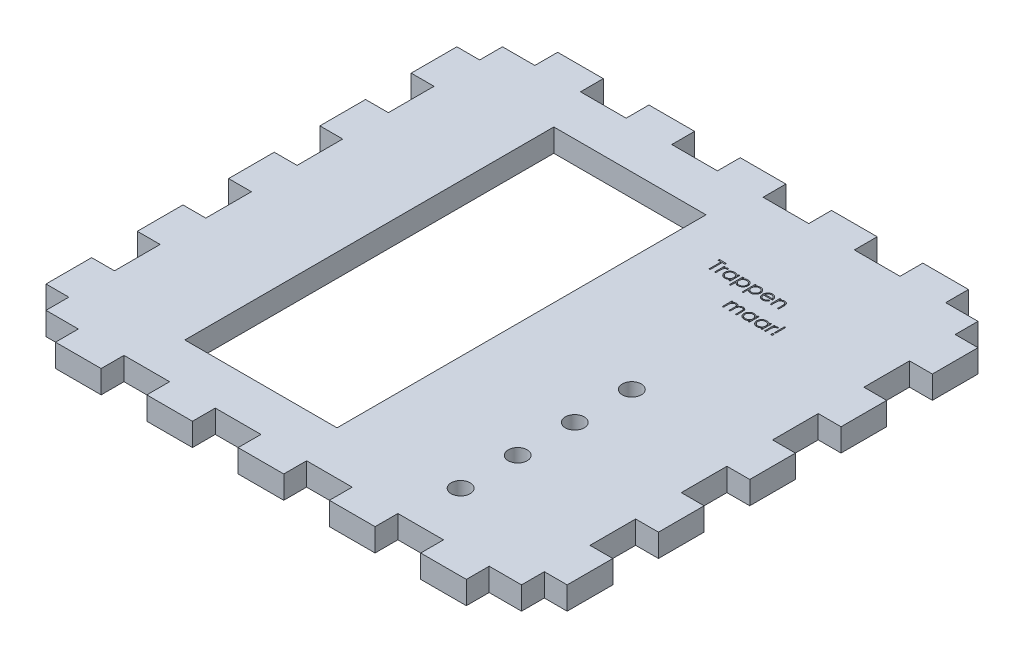
from build123d import *

# Parameters (mm, degrees)
SKETCH1_R           = 2.5
SKETCH1_W           = 40
SKETCH1_H           = 97
BOSS_EXTRUDE2_DEPTH = 6
SKETCH2_W           = 0.314102564
SKETCH2_H           = 2.692307693
CUT_EXTRUDE1_DEPTH  = 7


with BuildPart() as part:
    # Sketch1 → Boss-Extrude2 (new body)
    with BuildSketch(Plane(origin=(0, 0, 0), x_dir=(1, 0, 0), z_dir=(0, 1, 0))):
        Polygon((-62.5, -60), (-54, -60), (-54, -66), (-42, -66), (-42, -60), (-30, -60), (-30, -66), (-18, -66), (-18, -60), (-6, -60), (-6, -66), (6, -66), (6, -60), (18, -60), (18, -66), (30, -66), (30, -60), (42, -60), (42, -66), (54, -66), (54, -60), (62.5, -60), (62.5, -54), (68.5, -54), (68.5, -42), (62.5, -42), (62.5, -30), (68.5, -30), (68.5, -18), (62.5, -18), (62.5, -6), (68.5, -6), (68.5, 6), (62.5, 6), (62.5, 18), (68.5, 18), (68.5, 30), (62.5, 30), (62.5, 42), (68.5, 42), (68.5, 54), (62.5, 54), (62.5, 60), (54, 60), (54, 66), (42, 66), (42, 60), (30, 60), (30, 66), (18, 66), (18, 60), (6, 60), (6, 66), (-6, 66), (-6, 60), (-18, 60), (-18, 66), (-30, 66), (-30, 60), (-42, 60), (-42, 66), (-54, 66), (-54, 60), (-62.5, 60), (-62.5, 54), (-68.5, 54), (-68.5, 42), (-62.5, 42), (-62.5, 30), (-68.5, 30), (-68.5, 18), (-62.5, 18), (-62.5, 6), (-68.5, 6), (-68.5, -6), (-62.5, -6), (-62.5, -18), (-68.5, -18), (-68.5, -30), (-62.5, -30), (-62.5, -42), (-68.5, -42), (-68.5, -54), (-62.5, -54), align=None)
        with Locations((32.5, -46)):
            Circle(SKETCH1_R, mode=Mode.SUBTRACT)
        with Locations((32.5, -31)):
            Circle(SKETCH1_R, mode=Mode.SUBTRACT)
        with Locations((32.5, -16)):
            Circle(SKETCH1_R, mode=Mode.SUBTRACT)
        with Locations((32.5, -1)):
            Circle(SKETCH1_R, mode=Mode.SUBTRACT)
        with Locations((-17.5, 0)):
            Rectangle(SKETCH1_W, SKETCH1_H, mode=Mode.SUBTRACT)
    extrude(amount=BOSS_EXTRUDE2_DEPTH)

    # Sketch2 → Cut-Extrude1 (cut, through all)
    with BuildSketch(Plane(origin=(0, 6, 0), x_dir=(1, 0, 0), z_dir=(0, 1, 0))):
        Polygon((14.440306719, 39.731965066), (14.440306719, 40.090939425), (16.280050309, 40.090939425), (16.280050309, 39.731965066), (15.517229796, 39.731965066), (15.517229796, 36.590939425), (15.203127232, 36.590939425), (15.203127232, 39.731965066), align=None)
        with BuildLine():
            Line((16.639024668, 39.148631733), (16.953127232, 39.148631733))
            Line((16.953127232, 39.148631733), (16.953127232, 38.772129329))
            add(Edge.make_bspline(
                [(16.953127232, 38.772129329), (16.976315991, 38.807185157), (17.020664312, 38.874229157), (17.094377241, 38.962898458), (17.169880572, 39.036313504), (17.24753576, 39.094817023), (17.327913859, 39.138630142), (17.409250811, 39.170723177), (17.492826281, 39.189700492), (17.548988205, 39.192234151), (17.577125629, 39.193503528)],
                knots=[0, 0, 0, 0, 0.000126023, 0.000241017, 0.000345147, 0.000441342, 0.00053171, 0.000618946, 0.000702978, 0.000787349, 0.000787349, 0.000787349, 0.000787349], degree=3))
            add(Edge.make_bspline(
                [(17.577125629, 39.193503528), (17.598951956, 39.192313001), (17.643861041, 39.189863415), (17.711843631, 39.172652591), (17.781887083, 39.145174568), (17.82702947, 39.119334345), (17.850563129, 39.105863303)],
                knots=[0, 0, 0, 0, 6.5445e-05, 0.000134658, 0.00020926, 0.000290509, 0.000290509, 0.000290509, 0.000290509], degree=3))
            Line((17.850563129, 39.105863303), (17.678087168, 38.833828047))
            add(Edge.make_bspline(
                [(17.678087168, 38.833828047), (17.662978147, 38.840568313), (17.634298332, 38.853362628), (17.592343766, 38.868504639), (17.553662429, 38.877420554), (17.529018871, 38.878771272), (17.517530277, 38.879400964)],
                knots=[0, 0, 0, 0, 4.9621e-05, 9.4191e-05, 0.00013366, 0.000168129, 0.000168129, 0.000168129, 0.000168129], degree=3))
            add(Edge.make_bspline(
                [(17.517530277, 38.879400964), (17.492324543, 38.877720926), (17.440912153, 38.874294137), (17.365427654, 38.847355329), (17.292180448, 38.803830089), (17.234008786, 38.755558977), (17.188966533, 38.70901118), (17.156826308, 38.668362777), (17.127343561, 38.622784146), (17.09917334, 38.573054462), (17.073507046, 38.518324616), (17.049552377, 38.459141402), (17.027893514, 38.395436274), (17.01554327, 38.351053753), (17.009216976, 38.328319233)],
                knots=[0, 0, 0, 0, 7.549e-05, 0.000153978, 0.000237553, 0.000330197, 0.000379784, 0.000431685, 0.000485357, 0.000542493, 0.000603021, 0.000666557, 0.00073396, 0.000804745, 0.000804745, 0.000804745, 0.000804745], degree=3))
            add(Edge.make_bspline(
                [(17.009216976, 38.328319233), (17.004484582, 38.308042059), (16.99400269, 38.263129661), (16.983811153, 38.187781136), (16.973741635, 38.098757477), (16.966645016, 37.995810884), (16.960066974, 37.87919844), (16.956356892, 37.748742495), (16.953253751, 37.604309144), (16.953170685, 37.50333479), (16.953127232, 37.450514746)],
                knots=[0, 0, 0, 0, 6.2435e-05, 0.000138289, 0.000227871, 0.000331224, 0.000447781, 0.000578258, 0.000722716, 0.000881171, 0.000881171, 0.000881171, 0.000881171], degree=3))
            Line((16.953127232, 37.450514746), (16.953127232, 36.590939425))
            Line((16.953127232, 36.590939425), (16.639024668, 36.590939425))
            Line((16.639024668, 36.590939425), (16.639024668, 39.148631733))
        make_face()
        with BuildLine():
            Line((20.767229796, 39.148631733), (20.767229796, 36.590939425))
            Line((20.767229796, 36.590939425), (20.453127232, 36.590939425))
            Line((20.453127232, 36.590939425), (20.453127232, 37.033347278))
            add(Edge.make_bspline(
                [(20.453127232, 37.033347278), (20.417708441, 36.993307684), (20.348588226, 36.915169913), (20.233147108, 36.81308774), (20.11077893, 36.728709419), (19.982077609, 36.660559503), (19.847159366, 36.609367447), (19.706323278, 36.572981287), (19.559511898, 36.549587452), (19.459259543, 36.54725143), (19.408455758, 36.54606763)],
                knots=[0, 0, 0, 0, 0.000160263, 0.000312755, 0.000460949, 0.000605216, 0.000748578, 0.000892786, 0.001041028, 0.001193333, 0.001193333, 0.001193333, 0.001193333], degree=3))
            add(Edge.make_bspline(
                [(19.408455758, 36.54606763), (19.363287804, 36.547294002), (19.274214599, 36.549712463), (19.143185522, 36.568474767), (19.017093272, 36.598605388), (18.8958187, 36.640506278), (18.780146554, 36.696087099), (18.669086458, 36.762628347), (18.563213765, 36.841869177), (18.464142227, 36.932457206), (18.372910226, 37.030852193), (18.292848954, 37.13579774), (18.226095874, 37.246840044), (18.170275793, 37.362573198), (18.127279449, 37.483888117), (18.097305814, 37.610365285), (18.078565368, 37.741855159), (18.076147907, 37.831394682), (18.074922104, 37.876796797)],
                knots=[0, 0, 0, 0, 0.000135464, 0.00026714, 0.000396211, 0.000523931, 0.000651257, 0.000780517, 0.000911767, 0.001047265, 0.00118272, 0.001313831, 0.001442491, 0.001570752, 0.001698704, 0.001827775, 0.001960146, 0.00209631, 0.00209631, 0.00209631, 0.00209631], degree=3))
            add(Edge.make_bspline(
                [(18.074922104, 37.876796797), (18.076175075, 37.9212605), (18.078652132, 38.009162844), (18.097105352, 38.138441542), (18.12813636, 38.262959802), (18.171684208, 38.382316746), (18.227526163, 38.496656796), (18.29545425, 38.606060821), (18.375473375, 38.710830218), (18.467725782, 38.808501445), (18.567660552, 38.898722059), (18.674569283, 38.977131105), (18.785792564, 39.044847954), (18.903055575, 39.09850143), (19.02462268, 39.141910535), (19.151576125, 39.171943503), (19.283387704, 39.189640824), (19.372878196, 39.192203588), (19.418271463, 39.193503528)],
                knots=[0, 0, 0, 0, 0.000133363, 0.00026365, 0.000390846, 0.000517716, 0.000644083, 0.000771912, 0.000903449, 0.001038867, 0.001174416, 0.001306792, 0.001436052, 0.00156435, 0.001692963, 0.001822716, 0.001954992, 0.002091156, 0.002091156, 0.002091156, 0.002091156], degree=3))
            add(Edge.make_bspline(
                [(19.418271463, 39.193503528), (19.470471322, 39.192065776), (19.572832782, 39.189246413), (19.722560791, 39.165783686), (19.864205269, 39.126145219), (19.998859621, 39.072227721), (20.126040307, 39.000578992), (20.244543291, 38.910199031), (20.355608775, 38.801657844), (20.419989066, 38.718287399), (20.453127232, 38.675374521)],
                knots=[0, 0, 0, 0, 0.00015654, 0.000306968, 0.000453261, 0.000596998, 0.000741098, 0.000889738, 0.001042937, 0.001205434, 0.001205434, 0.001205434, 0.001205434], degree=3))
            Line((20.453127232, 38.675374521), (20.453127232, 39.148631733))
            Line((20.453127232, 39.148631733), (20.767229796, 39.148631733))
        make_face()
        with BuildLine():
            add(Edge.make_bspline(
                [(19.422478193, 38.879400964), (19.376563856, 38.877767326), (19.285936256, 38.874542785), (19.152892254, 38.84936929), (19.025578839, 38.807484695), (18.904632765, 38.750202794), (18.791964549, 38.678174057), (18.691270878, 38.591052674), (18.601728176, 38.49121566), (18.526419912, 38.37911355), (18.465029415, 38.258935459), (18.421862383, 38.13331102), (18.393393136, 38.004506043), (18.390484615, 37.917143357), (18.389024668, 37.873291188)],
                knots=[0, 0, 0, 0, 0.000137677, 0.000271753, 0.000404561, 0.000538791, 0.000672205, 0.000804452, 0.00093703, 0.001073348, 0.00120849, 0.001340643, 0.001470999, 0.001602378, 0.001602378, 0.001602378, 0.001602378], degree=3))
            add(Edge.make_bspline(
                [(18.389024668, 37.873291188), (18.390889561, 37.829701081), (18.394612038, 37.742691725), (18.421362732, 37.613711148), (18.466242606, 37.488057106), (18.527484669, 37.366796113), (18.604171293, 37.254212012), (18.693059946, 37.15247189), (18.795010227, 37.064982301), (18.907937734, 36.991744728), (19.028545705, 36.932582207), (19.155379636, 36.891416567), (19.286055274, 36.864838787), (19.374907608, 36.86173431), (19.419673706, 36.860170194)],
                knots=[0, 0, 0, 0, 0.000130727, 0.000260941, 0.000393327, 0.000530037, 0.000667328, 0.000800955, 0.000934191, 0.001068956, 0.001203792, 0.001335934, 0.001468075, 0.001602253, 0.001602253, 0.001602253, 0.001602253], degree=3))
            add(Edge.make_bspline(
                [(19.419673706, 36.860170194), (19.465120209, 36.861830158), (19.555508796, 36.865131662), (19.688947503, 36.890412927), (19.818442466, 36.932181726), (19.942229695, 36.990080852), (20.057545826, 37.061838208), (20.161043703, 37.145845299), (20.248559672, 37.243548483), (20.322752281, 37.350924936), (20.380927698, 37.468636933), (20.423303757, 37.593971124), (20.448357663, 37.726931872), (20.451515393, 37.817795799), (20.453127232, 37.864176605)],
                knots=[0, 0, 0, 0, 0.000136278, 0.000271043, 0.000405851, 0.000543552, 0.000679927, 0.000812429, 0.000941985, 0.001072088, 0.00120284, 0.001334538, 0.001467925, 0.001607002, 0.001607002, 0.001607002, 0.001607002], degree=3))
            add(Edge.make_bspline(
                [(20.453127232, 37.864176605), (20.452167576, 37.899514435), (20.450278668, 37.969070468), (20.435848099, 38.071197986), (20.412893172, 38.168931712), (20.380547002, 38.262374401), (20.338055718, 38.351009416), (20.286807952, 38.435473177), (20.225902502, 38.515326388), (20.156319806, 38.589469459), (20.080154604, 38.657095921), (19.999560063, 38.717460162), (19.913581316, 38.767048935), (19.823664279, 38.808090206), (19.729652945, 38.840749356), (19.630782325, 38.86253705), (19.528103338, 38.877497371), (19.458057282, 38.878759752), (19.422478193, 38.879400964)],
                knots=[0, 0, 0, 0, 0.000105983, 0.000208608, 0.000308773, 0.00040678, 0.000504626, 0.000603105, 0.000702667, 0.00080535, 0.000907651, 0.001007914, 0.001106881, 0.00120477, 0.001304102, 0.001404791, 0.00150811, 0.001614764, 0.001614764, 0.001614764, 0.001614764], degree=3))
        make_face(mode=Mode.SUBTRACT)
        with BuildLine():
            Line((21.485178514, 39.148631733), (21.799281078, 39.148631733))
            Line((21.799281078, 39.148631733), (21.799281078, 38.675374521))
            add(Edge.make_bspline(
                [(21.799281078, 38.675374521), (21.832638562, 38.718312255), (21.897462157, 38.801753148), (22.009187062, 38.909743277), (22.127113871, 39.00081858), (22.254277283, 39.072201113), (22.388700973, 39.126021925), (22.529833291, 39.165801375), (22.678872055, 39.18924285), (22.780768508, 39.192064511), (22.832734604, 39.193503528)],
                knots=[0, 0, 0, 0, 0.00016294, 0.00031664, 0.000464722, 0.000608822, 0.000752559, 0.000898176, 0.001047911, 0.001203751, 0.001203751, 0.001203751, 0.001203751], degree=3))
            add(Edge.make_bspline(
                [(22.832734604, 39.193503528), (22.878126207, 39.192190349), (22.967845095, 39.189594782), (23.099908324, 39.172021727), (23.227083708, 39.141904035), (23.348651762, 39.098503119), (23.465914827, 39.044847649), (23.577136927, 38.977130614), (23.684050482, 38.898724423), (23.783966671, 38.808492272), (23.876288039, 38.710864006), (23.95613422, 38.605841702), (24.025006124, 38.496879115), (24.080676421, 38.382287023), (24.124284768, 38.262967793), (24.155299446, 38.138439352), (24.173757089, 38.009163412), (24.176233541, 37.921260691), (24.177486206, 37.876796797)],
                knots=[0, 0, 0, 0, 0.000136164, 0.000269135, 0.000398888, 0.000527501, 0.000655799, 0.000785059, 0.000917435, 0.001052984, 0.001188402, 0.001319939, 0.001448139, 0.001574506, 0.001701376, 0.001828571, 0.001958859, 0.002092222, 0.002092222, 0.002092222, 0.002092222], degree=3))
            add(Edge.make_bspline(
                [(24.177486206, 37.876796797), (24.176260721, 37.831394488), (24.173843886, 37.741854584), (24.15509888, 37.610367487), (24.125142006, 37.483880113), (24.082083823, 37.362602849), (24.026442335, 37.246619198), (23.958737774, 37.136012802), (23.878851307, 37.030819099), (23.78755018, 36.932466199), (23.688497244, 36.841866886), (23.582619754, 36.762628816), (23.471560829, 36.696087441), (23.355888661, 36.640504481), (23.234613023, 36.598612297), (23.108299745, 36.568394497), (22.977017599, 36.549760001), (22.887716447, 36.547307858), (22.842550309, 36.54606763)],
                knots=[0, 0, 0, 0, 0.000136164, 0.000268535, 0.000397606, 0.000525558, 0.00065382, 0.000782843, 0.000913955, 0.001049409, 0.001184907, 0.001316158, 0.001445417, 0.001572744, 0.001700463, 0.001829535, 0.001961906, 0.002097369, 0.002097369, 0.002097369, 0.002097369], degree=3))
            add(Edge.make_bspline(
                [(22.842550309, 36.54606763), (22.791722737, 36.547362438), (22.691323381, 36.549920063), (22.54452571, 36.575839473), (22.403248859, 36.614576408), (22.269058034, 36.671275402), (22.140890221, 36.743530918), (22.019470416, 36.831641124), (21.904153663, 36.935421749), (21.834744905, 37.014153565), (21.799281078, 37.054380932)],
                knots=[0, 0, 0, 0, 0.000152339, 0.000300914, 0.000445856, 0.000591043, 0.000736709, 0.000886352, 0.001040245, 0.001201023, 0.001201023, 0.001201023, 0.001201023], degree=3))
            Line((21.799281078, 37.054380932), (21.799281078, 35.648631733))
            Line((21.799281078, 35.648631733), (21.485178514, 35.648631733))
            Line((21.485178514, 35.648631733), (21.485178514, 39.148631733))
        make_face()
        with BuildLine():
            add(Edge.make_bspline(
                [(22.829930117, 38.879400964), (22.794350554, 38.878760705), (22.724303566, 38.877500202), (22.621631347, 38.862526253), (22.52273592, 38.840788512), (22.428613968, 38.807876612), (22.338363352, 38.767477799), (22.252679187, 38.716995787), (22.171621619, 38.657343782), (22.095394589, 38.589664438), (22.026531296, 38.515089749), (21.965568368, 38.43550194), (21.914361062, 38.351001801), (21.871859042, 38.262376438), (21.83951576, 38.168931153), (21.81656004, 38.07119814), (21.802129687, 37.969070428), (21.80024075, 37.899514421), (21.799281078, 37.864176605)],
                knots=[0, 0, 0, 0, 0.000106654, 0.000209973, 0.000310662, 0.000409994, 0.000508521, 0.000606883, 0.00070771, 0.000810012, 0.000912217, 0.001011779, 0.001110258, 0.001208104, 0.001306111, 0.001406276, 0.001508901, 0.001614884, 0.001614884, 0.001614884, 0.001614884], degree=3))
            add(Edge.make_bspline(
                [(21.799281078, 37.864176605), (21.800871934, 37.817788492), (21.803988556, 37.726910251), (21.829325924, 37.594126129), (21.870561188, 37.468474473), (21.929089902, 37.351013436), (22.003037476, 37.243030601), (22.092135632, 37.146339995), (22.195578183, 37.061549404), (22.311645375, 36.99012815), (22.436067506, 36.932140084), (22.565853418, 36.890625873), (22.699218299, 36.865053645), (22.789386618, 36.861806826), (22.834837969, 36.860170194)],
                knots=[0, 0, 0, 0, 0.000139077, 0.000272463, 0.00040394, 0.000534691, 0.000664794, 0.000795295, 0.000927798, 0.001064768, 0.001203104, 0.001338581, 0.001472656, 0.001608934, 0.001608934, 0.001608934, 0.001608934], degree=3))
            add(Edge.make_bspline(
                [(22.834837969, 36.860170194), (22.879373737, 36.861726571), (22.96776923, 36.8648157), (23.097927352, 36.891553887), (23.22441799, 36.932398912), (23.344598162, 36.991958468), (23.45742165, 37.064948526), (23.559303204, 37.152508559), (23.648310117, 37.253998502), (23.724174472, 37.367007005), (23.785305958, 37.488182389), (23.831236198, 37.613563778), (23.857744771, 37.742709201), (23.861501559, 37.829706914), (23.863383642, 37.873291188)],
                knots=[0, 0, 0, 0, 0.000133479, 0.000264931, 0.000397073, 0.000531279, 0.000666044, 0.000799279, 0.000932907, 0.001069805, 0.001206515, 0.001339137, 0.001469351, 0.001600078, 0.001600078, 0.001600078, 0.001600078], degree=3))
            add(Edge.make_bspline(
                [(23.863383642, 37.873291188), (23.861928908, 37.917146177), (23.859030775, 38.004514481), (23.830483737, 38.133277384), (23.787583759, 38.25916536), (23.725024707, 38.37868591), (23.650823438, 38.491459992), (23.561076441, 38.591013871), (23.460460244, 38.678184544), (23.34777108, 38.750199954), (23.226830655, 38.807485449), (23.099515739, 38.849369088), (22.966472137, 38.874542837), (22.875844482, 38.877767343), (22.829930117, 38.879400964)],
                knots=[0, 0, 0, 0, 0.000131379, 0.000261735, 0.000393889, 0.000529349, 0.000665274, 0.000797853, 0.0009301, 0.001063514, 0.001197743, 0.001330552, 0.001464627, 0.001602305, 0.001602305, 0.001602305, 0.001602305], degree=3))
        make_face(mode=Mode.SUBTRACT)
        with BuildLine():
            Line((24.805691335, 39.148631733), (25.119793899, 39.148631733))
            Line((25.119793899, 39.148631733), (25.119793899, 38.675374521))
            add(Edge.make_bspline(
                [(25.119793899, 38.675374521), (25.153151383, 38.718312255), (25.217974977, 38.801753148), (25.329699882, 38.909743277), (25.447626691, 39.00081858), (25.574790104, 39.072201113), (25.709213794, 39.126021925), (25.850346111, 39.165801375), (25.999384876, 39.18924285), (26.101281329, 39.192064511), (26.153247424, 39.193503528)],
                knots=[0, 0, 0, 0, 0.00016294, 0.00031664, 0.000464722, 0.000608822, 0.000752559, 0.000898176, 0.001047911, 0.001203751, 0.001203751, 0.001203751, 0.001203751], degree=3))
            add(Edge.make_bspline(
                [(26.153247424, 39.193503528), (26.198639027, 39.192190349), (26.288357916, 39.189594782), (26.420421145, 39.172021727), (26.547596528, 39.141904035), (26.669164582, 39.098503119), (26.786427647, 39.044847649), (26.897649747, 38.977130614), (27.004563303, 38.898724423), (27.104479492, 38.808492272), (27.196800859, 38.710864006), (27.276647041, 38.605841702), (27.345518945, 38.496879115), (27.401189241, 38.382287023), (27.444797589, 38.262967793), (27.475812266, 38.138439352), (27.49426991, 38.009163412), (27.496746362, 37.921260691), (27.497999027, 37.876796797)],
                knots=[0, 0, 0, 0, 0.000136164, 0.000269135, 0.000398888, 0.000527501, 0.000655799, 0.000785059, 0.000917435, 0.001052984, 0.001188402, 0.001319939, 0.001448139, 0.001574506, 0.001701376, 0.001828571, 0.001958859, 0.002092222, 0.002092222, 0.002092222, 0.002092222], degree=3))
            add(Edge.make_bspline(
                [(27.497999027, 37.876796797), (27.496773541, 37.831394488), (27.494356707, 37.741854584), (27.475611701, 37.610367487), (27.445654827, 37.483880113), (27.402596644, 37.362602849), (27.346955155, 37.246619198), (27.279250595, 37.136012802), (27.199364128, 37.030819099), (27.108063, 36.932466199), (27.009010064, 36.841866886), (26.903132575, 36.762628816), (26.792073649, 36.696087441), (26.676401482, 36.640504481), (26.555125843, 36.598612297), (26.428812566, 36.568394497), (26.297530419, 36.549760001), (26.208229267, 36.547307858), (26.163063129, 36.54606763)],
                knots=[0, 0, 0, 0, 0.000136164, 0.000268535, 0.000397606, 0.000525558, 0.00065382, 0.000782843, 0.000913955, 0.001049409, 0.001184907, 0.001316158, 0.001445417, 0.001572744, 0.001700463, 0.001829535, 0.001961906, 0.002097369, 0.002097369, 0.002097369, 0.002097369], degree=3))
            add(Edge.make_bspline(
                [(26.163063129, 36.54606763), (26.112235557, 36.547362438), (26.011836201, 36.549920063), (25.865038531, 36.575839473), (25.723761679, 36.614576408), (25.589570854, 36.671275402), (25.461403042, 36.743530918), (25.339983236, 36.831641124), (25.224666483, 36.935421749), (25.155257726, 37.014153565), (25.119793899, 37.054380932)],
                knots=[0, 0, 0, 0, 0.000152339, 0.000300914, 0.000445856, 0.000591043, 0.000736709, 0.000886352, 0.001040245, 0.001201023, 0.001201023, 0.001201023, 0.001201023], degree=3))
            Line((25.119793899, 37.054380932), (25.119793899, 35.648631733))
            Line((25.119793899, 35.648631733), (24.805691335, 35.648631733))
            Line((24.805691335, 35.648631733), (24.805691335, 39.148631733))
        make_face()
        with BuildLine():
            add(Edge.make_bspline(
                [(26.150442937, 38.879400964), (26.114863375, 38.878760705), (26.044816387, 38.877500202), (25.942144168, 38.862526253), (25.84324874, 38.840788512), (25.749126789, 38.807876612), (25.658876172, 38.767477799), (25.573192007, 38.716995787), (25.49213444, 38.657343782), (25.415907409, 38.589664438), (25.347044116, 38.515089749), (25.286081188, 38.43550194), (25.234873883, 38.351001801), (25.192371863, 38.262376438), (25.16002858, 38.168931153), (25.13707286, 38.07119814), (25.122642507, 37.969070428), (25.12075357, 37.899514421), (25.119793899, 37.864176605)],
                knots=[0, 0, 0, 0, 0.000106654, 0.000209973, 0.000310662, 0.000409994, 0.000508521, 0.000606883, 0.00070771, 0.000810012, 0.000912217, 0.001011779, 0.001110258, 0.001208104, 0.001306111, 0.001406276, 0.001508901, 0.001614884, 0.001614884, 0.001614884, 0.001614884], degree=3))
            add(Edge.make_bspline(
                [(25.119793899, 37.864176605), (25.121384755, 37.817788492), (25.124501377, 37.726910251), (25.149838745, 37.594126129), (25.191074009, 37.468474473), (25.249602722, 37.351013436), (25.323550297, 37.243030601), (25.412648453, 37.146339995), (25.516091004, 37.061549404), (25.632158196, 36.99012815), (25.756580326, 36.932140084), (25.886366238, 36.890625873), (26.019731119, 36.865053645), (26.109899439, 36.861806826), (26.15535079, 36.860170194)],
                knots=[0, 0, 0, 0, 0.000139077, 0.000272463, 0.00040394, 0.000534691, 0.000664794, 0.000795295, 0.000927798, 0.001064768, 0.001203104, 0.001338581, 0.001472656, 0.001608934, 0.001608934, 0.001608934, 0.001608934], degree=3))
            add(Edge.make_bspline(
                [(26.15535079, 36.860170194), (26.199886558, 36.861726571), (26.288282051, 36.8648157), (26.418440172, 36.891553887), (26.54493081, 36.932398912), (26.665110983, 36.991958468), (26.777934471, 37.064948526), (26.879816024, 37.152508559), (26.968822938, 37.253998502), (27.044687293, 37.367007005), (27.105818778, 37.488182389), (27.151749018, 37.613563778), (27.178257591, 37.742709201), (27.18201438, 37.829706914), (27.183896463, 37.873291188)],
                knots=[0, 0, 0, 0, 0.000133479, 0.000264931, 0.000397073, 0.000531279, 0.000666044, 0.000799279, 0.000932907, 0.001069805, 0.001206515, 0.001339137, 0.001469351, 0.001600078, 0.001600078, 0.001600078, 0.001600078], degree=3))
            add(Edge.make_bspline(
                [(27.183896463, 37.873291188), (27.182441729, 37.917146177), (27.179543595, 38.004514481), (27.150996557, 38.133277384), (27.10809658, 38.25916536), (27.045537528, 38.37868591), (26.971336258, 38.491459992), (26.881589261, 38.591013871), (26.780973065, 38.678184544), (26.668283901, 38.750199954), (26.547343475, 38.807485449), (26.42002856, 38.849369088), (26.286984957, 38.874542837), (26.196357303, 38.877767343), (26.150442937, 38.879400964)],
                knots=[0, 0, 0, 0, 0.000131379, 0.000261735, 0.000393889, 0.000529349, 0.000665274, 0.000797853, 0.0009301, 0.001063514, 0.001197743, 0.001330552, 0.001464627, 0.001602305, 0.001602305, 0.001602305, 0.001602305], degree=3))
        make_face(mode=Mode.SUBTRACT)
        with BuildLine():
            Line((30.225362809, 37.398631733), (30.504409283, 37.252097278))
            add(Edge.make_bspline(
                [(30.504409283, 37.252097278), (30.482172688, 37.212653946), (30.43890908, 37.135912844), (30.364508332, 37.030480983), (30.286516259, 36.935633267), (30.201412291, 36.853903613), (30.111742612, 36.782652228), (30.017009957, 36.720314403), (29.91672114, 36.667195883), (29.810871415, 36.622443355), (29.698571864, 36.588033861), (29.579550347, 36.56372964), (29.453578852, 36.548706371), (29.367232672, 36.546961231), (29.323019059, 36.54606763)],
                knots=[0, 0, 0, 0, 0.000135759, 0.000264133, 0.000386579, 0.000503597, 0.000617365, 0.000729763, 0.000843304, 0.000957371, 0.001074023, 0.001195027, 0.001321389, 0.001453992, 0.001453992, 0.001453992, 0.001453992], degree=3))
            add(Edge.make_bspline(
                [(29.323019059, 36.54606763), (29.273877081, 36.547214806), (29.17801532, 36.549452612), (29.038475573, 36.568745077), (28.907096154, 36.600217435), (28.783884451, 36.644182977), (28.669142198, 36.701610301), (28.562641343, 36.771569783), (28.463821818, 36.853702037), (28.375797608, 36.948718481), (28.296553726, 37.050400438), (28.226627906, 37.156356323), (28.168170475, 37.266319547), (28.120617864, 37.379590071), (28.082212999, 37.495453965), (28.055446296, 37.614965432), (28.040016548, 37.737801017), (28.037652102, 37.820898352), (28.036460565, 37.862774361)],
                knots=[0, 0, 0, 0, 0.000147371, 0.000287478, 0.000421649, 0.000552053, 0.000679042, 0.000805636, 0.000933558, 0.00106351, 0.001193382, 0.001319977, 0.001443869, 0.001566405, 0.001688128, 0.001809576, 0.001933238, 0.002058864, 0.002058864, 0.002058864, 0.002058864], degree=3))
            add(Edge.make_bspline(
                [(28.036460565, 37.862774361), (28.037519707, 37.902069191), (28.039618785, 37.979946356), (28.052849572, 38.095211901), (28.076297865, 38.207240353), (28.108474189, 38.316124801), (28.150025435, 38.421682935), (28.200857655, 38.523978999), (28.261050032, 38.622904139), (28.307522706, 38.685307272), (28.330931719, 38.716740707)],
                knots=[0, 0, 0, 0, 0.000117891, 0.000233644, 0.000347498, 0.000460856, 0.000573868, 0.000687374, 0.000803169, 0.000920699, 0.000920699, 0.000920699, 0.000920699], degree=3))
            add(Edge.make_bspline(
                [(28.330931719, 38.716740707), (28.362639402, 38.754609577), (28.425050349, 38.829147728), (28.530606704, 38.927086053), (28.6449069, 39.009129829), (28.766518526, 39.077136965), (28.896855, 39.128810612), (29.034164291, 39.167318194), (29.180009878, 39.188896205), (29.279715098, 39.191944039), (29.330731399, 39.193503528)],
                knots=[0, 0, 0, 0, 0.000148071, 0.000291452, 0.00043058, 0.000569298, 0.000708346, 0.00085021, 0.000996268, 0.001149307, 0.001149307, 0.001149307, 0.001149307], degree=3))
            add(Edge.make_bspline(
                [(29.330731399, 39.193503528), (29.383179004, 39.192149479), (29.48606925, 39.189493143), (29.636101371, 39.16486681), (29.778062087, 39.125814256), (29.911894592, 39.070660465), (30.037612453, 38.999500913), (30.154398502, 38.911359072), (30.264250015, 38.808940985), (30.328158593, 38.730177775), (30.360679315, 38.690098079)],
                knots=[0, 0, 0, 0, 0.000157241, 0.00030847, 0.000454763, 0.000598116, 0.000741606, 0.000886879, 0.001036172, 0.001190853, 0.001190853, 0.001190853, 0.001190853], degree=3))
            add(Edge.make_bspline(
                [(30.360679315, 38.690098079), (30.382806254, 38.659894498), (30.426912847, 38.599688379), (30.482159947, 38.501517222), (30.530117342, 38.398806627), (30.568450303, 38.28989633), (30.599489804, 38.17607675), (30.621946623, 38.056534205), (30.635116241, 37.931304294), (30.637704939, 37.845977739), (30.639024668, 37.802477887)],
                knots=[0, 0, 0, 0, 0.000112234, 0.000223721, 0.000337279, 0.000451932, 0.000569628, 0.000690912, 0.000816421, 0.00094695, 0.00094695, 0.00094695, 0.00094695], degree=3))
            Line((30.639024668, 37.802477887), (28.350563129, 37.802477887))
            add(Edge.make_bspline(
                [(28.350563129, 37.802477887), (28.352102736, 37.768777422), (28.35513031, 37.702506819), (28.369245453, 37.605536036), (28.391494227, 37.513162693), (28.422763289, 37.426079651), (28.460630135, 37.343149524), (28.507015851, 37.264987487), (28.562355405, 37.191949557), (28.624081105, 37.123382419), (28.6927882, 37.062321658), (28.765070947, 37.007669882), (28.841964512, 36.961864285), (28.922862596, 36.924684395), (29.007634381, 36.895578079), (29.096306576, 36.875710259), (29.188704692, 36.862403152), (29.251690426, 36.860923487), (29.283756238, 36.860170194)],
                knots=[0, 0, 0, 0, 0.000101159, 0.000198924, 0.000293472, 0.000385722, 0.000476069, 0.000566611, 0.000657757, 0.000750573, 0.000842919, 0.000933083, 0.001022062, 0.001110842, 0.001199752, 0.001290403, 0.001383113, 0.001479259, 0.001479259, 0.001479259, 0.001479259], degree=3))
            add(Edge.make_bspline(
                [(29.283756238, 36.860170194), (29.315107386, 36.860778251), (29.377314077, 36.861984752), (29.469954934, 36.873716663), (29.561094462, 36.892686939), (29.650355445, 36.918576929), (29.735926291, 36.950153781), (29.815171841, 36.988256638), (29.888052057, 37.030406385), (29.956169023, 37.07861606), (30.022240016, 37.137624247), (30.087782503, 37.211259968), (30.158059156, 37.298347496), (30.202048749, 37.363893162), (30.225362809, 37.398631733)],
                knots=[0, 0, 0, 0, 9.4016e-05, 0.000186545, 0.000279636, 0.000373054, 0.000465125, 0.000552934, 0.000636508, 0.000717442, 0.000802858, 0.000901616, 0.001012865, 0.001138311, 0.001138311, 0.001138311, 0.001138311], degree=3))
        make_face()
        with BuildLine():
            add(Edge.make_bspline(
                [(30.324922104, 38.116580451), (30.313425479, 38.158243324), (30.291298178, 38.238430945), (30.245061813, 38.349471835), (30.192990273, 38.448159736), (30.131368541, 38.53373937), (30.061549816, 38.609742883), (29.980904633, 38.676161468), (29.890468739, 38.735578919), (29.790709599, 38.785731418), (29.685067814, 38.828421277), (29.574461622, 38.857046393), (29.461603834, 38.876655935), (29.385269547, 38.878482043), (29.3468572, 38.879400964)],
                knots=[0, 0, 0, 0, 0.000129543, 0.000249328, 0.000360065, 0.000463575, 0.000564789, 0.000668832, 0.000776175, 0.000888744, 0.001003316, 0.001117263, 0.001230914, 0.001346035, 0.001346035, 0.001346035, 0.001346035], degree=3))
            add(Edge.make_bspline(
                [(29.3468572, 38.879400964), (29.315507761, 38.878789292), (29.253536512, 38.877580146), (29.162235444, 38.866110017), (29.074555745, 38.847150172), (28.989850458, 38.821185215), (28.909229589, 38.786576613), (28.831034821, 38.745993386), (28.757254425, 38.696451802), (28.711113129, 38.658692947), (28.687802713, 38.63961731)],
                knots=[0, 0, 0, 0, 9.4016e-05, 0.000185849, 0.000275511, 0.000362884, 0.000451173, 0.00053836, 0.000626838, 0.000717174, 0.000717174, 0.000717174, 0.000717174], degree=3))
            add(Edge.make_bspline(
                [(28.687802713, 38.63961731), (28.671109431, 38.624522994), (28.637326297, 38.593975778), (28.592185775, 38.541346571), (28.548965302, 38.484595009), (28.50963165, 38.421549885), (28.473554063, 38.352929106), (28.439794086, 38.27931147), (28.409407674, 38.20013834), (28.392311564, 38.144965901), (28.383515854, 38.116580451)],
                knots=[0, 0, 0, 0, 6.7454e-05, 0.00013651, 0.000207604, 0.000281328, 0.000359112, 0.000440057, 0.000524171, 0.000613305, 0.000613305, 0.000613305, 0.000613305], degree=3))
            Line((28.383515854, 38.116580451), (30.324922104, 38.116580451))
        make_face(mode=Mode.SUBTRACT)
        with BuildLine():
            Line((31.267229796, 39.148631733), (31.58133236, 39.148631733))
            Line((31.58133236, 39.148631733), (31.58133236, 38.687293592))
            add(Edge.make_bspline(
                [(31.58133236, 38.687293592), (31.614869995, 38.729136315), (31.679950946, 38.810333578), (31.78833528, 38.917054153), (31.90287918, 39.004999378), (32.022881183, 39.075103172), (32.148504194, 39.127949798), (32.278982463, 39.166115729), (32.41509717, 39.189000557), (32.507661606, 39.191990788), (32.554489411, 39.193503528)],
                knots=[0, 0, 0, 0, 0.000160777, 0.000311994, 0.000455029, 0.000592958, 0.000727738, 0.000862858, 0.001000022, 0.001140458, 0.001140458, 0.001140458, 0.001140458], degree=3))
            add(Edge.make_bspline(
                [(32.554489411, 39.193503528), (32.601820046, 39.191758332), (32.694457513, 39.188342564), (32.829335575, 39.161325873), (32.955308968, 39.115180618), (33.071928524, 39.051968547), (33.177055738, 38.973362074), (33.269380589, 38.881784292), (33.345743836, 38.776448209), (33.396941199, 38.678725052), (33.430666847, 38.592036258), (33.451899185, 38.517789508), (33.469930166, 38.435071357), (33.485561914, 38.344131768), (33.496139026, 38.244333578), (33.504481317, 38.136085886), (33.510460012, 38.019423755), (33.510697219, 37.938737128), (33.51081954, 37.897129329)],
                knots=[0, 0, 0, 0, 0.00014192, 0.000277771, 0.000410631, 0.000543023, 0.000674273, 0.000803173, 0.000931629, 0.001063031, 0.00113295, 0.001210382, 0.001294414, 0.001386856, 0.001487045, 0.001595345, 0.001712567, 0.001837375, 0.001837375, 0.001837375, 0.001837375], degree=3))
            Line((33.51081954, 37.897129329), (33.51081954, 36.590939425))
            Line((33.51081954, 36.590939425), (33.196716976, 36.590939425))
            Line((33.196716976, 36.590939425), (33.196716976, 37.794064425))
            add(Edge.make_bspline(
                [(33.196716976, 37.794064425), (33.196523768, 37.82888687), (33.196154193, 37.895496281), (33.194988547, 37.990865304), (33.19217874, 38.077351882), (33.188230427, 38.15474925), (33.182451397, 38.222983086), (33.176428765, 38.282192363), (33.169063789, 38.332301906), (33.162500875, 38.362466988), (33.15955752, 38.375995515)],
                knots=[0, 0, 0, 0, 0.00010447, 0.000199832, 0.000286116, 0.000364054, 0.000432294, 0.000491525, 0.000542592, 0.000584118, 0.000584118, 0.000584118, 0.000584118], degree=3))
            add(Edge.make_bspline(
                [(33.15955752, 38.375995515), (33.148931989, 38.4157067), (33.128481128, 38.492138444), (33.077947145, 38.595812797), (33.014132964, 38.684010985), (32.936235115, 38.756187706), (32.845006039, 38.812358543), (32.740698897, 38.851332498), (32.624320256, 38.875708767), (32.542465873, 38.878135899), (32.499801911, 38.879400964)],
                knots=[0, 0, 0, 0, 0.000123096, 0.000236922, 0.000343781, 0.000447968, 0.000553428, 0.000663063, 0.000780492, 0.000908329, 0.000908329, 0.000908329, 0.000908329], degree=3))
            add(Edge.make_bspline(
                [(32.499801911, 38.879400964), (32.474534228, 38.878924959), (32.424530135, 38.877982958), (32.350380163, 38.86853166), (32.27845599, 38.853073204), (32.208035781, 38.832204567), (32.140527987, 38.803542298), (32.073763696, 38.771012927), (32.010256932, 38.730464715), (31.948653535, 38.685274094), (31.891340727, 38.635194887), (31.838012389, 38.582350377), (31.790474368, 38.526074773), (31.747405693, 38.467274825), (31.71022743, 38.405142987), (31.677774342, 38.340278681), (31.650238647, 38.272596532), (31.636555954, 38.225621471), (31.629709764, 38.20211731)],
                knots=[0, 0, 0, 0, 7.5773e-05, 0.000149953, 0.000223797, 0.000296325, 0.00036989, 0.000443574, 0.000518859, 0.000595564, 0.000672601, 0.000746967, 0.000820581, 0.000893366, 0.000965391, 0.001037508, 0.001110807, 0.001184211, 0.001184211, 0.001184211, 0.001184211], degree=3))
            add(Edge.make_bspline(
                [(31.629709764, 38.20211731), (31.625770115, 38.184862107), (31.617193707, 38.147298432), (31.607930527, 38.085654013), (31.599522951, 38.014344038), (31.592485993, 37.933451721), (31.588180576, 37.842693846), (31.583486179, 37.742458008), (31.581777118, 37.63234452), (31.581484764, 37.555682827), (31.58133236, 37.515719073)],
                knots=[0, 0, 0, 0, 5.3082e-05, 0.000115557, 0.000186868, 0.0002685, 0.000359077, 0.000459426, 0.000569522, 0.000689416, 0.000689416, 0.000689416, 0.000689416], degree=3))
            Line((31.58133236, 37.515719073), (31.58133236, 36.590939425))
            Line((31.58133236, 36.590939425), (31.267229796, 36.590939425))
            Line((31.267229796, 36.590939425), (31.267229796, 39.148631733))
        make_face()
        with BuildLine():
            Line((25.523640052, 32.315298399), (25.837742617, 32.315298399))
            Line((25.837742617, 32.315298399), (25.837742617, 31.870787182))
            add(Edge.make_bspline(
                [(25.837742617, 31.870787182), (25.866026566, 31.909674783), (25.920221326, 31.984187156), (26.009086979, 32.082377441), (26.097863091, 32.165705595), (26.161796473, 32.209448467), (26.192510245, 32.230462662)],
                knots=[0, 0, 0, 0, 0.000144152, 0.000276209, 0.000396804, 0.000508302, 0.000508302, 0.000508302, 0.000508302], degree=3))
            add(Edge.make_bspline(
                [(26.192510245, 32.230462662), (26.234374907, 32.250468028), (26.317372807, 32.290129241), (26.448792032, 32.3303628), (26.583266701, 32.355087901), (26.674074915, 32.358469275), (26.719753835, 32.360170194)],
                knots=[0, 0, 0, 0, 0.000139031, 0.000275633, 0.000410962, 0.000547939, 0.000547939, 0.000547939, 0.000547939], degree=3))
            add(Edge.make_bspline(
                [(26.719753835, 32.360170194), (26.750646831, 32.359124904), (26.81178241, 32.357056329), (26.9023665, 32.343596294), (26.990225112, 32.320330121), (27.074839141, 32.287922797), (27.154559821, 32.24867611), (27.227649018, 32.202626402), (27.293273227, 32.150929327), (27.351399278, 32.091250394), (27.403668303, 32.021913795), (27.45174715, 31.941049546), (27.496172362, 31.846841885), (27.520793671, 31.778475344), (27.533756238, 31.742481893)],
                knots=[0, 0, 0, 0, 9.2678e-05, 0.000183405, 0.000274048, 0.000364807, 0.000454797, 0.00054019, 0.000623517, 0.000704829, 0.000789387, 0.000883415, 0.000986597, 0.001101318, 0.001101318, 0.001101318, 0.001101318], degree=3))
            add(Edge.make_bspline(
                [(27.533756238, 31.742481893), (27.54746749, 31.767206312), (27.574449307, 31.815860497), (27.619754944, 31.88471876), (27.66722274, 31.949125551), (27.717257233, 32.009131976), (27.76968182, 32.064441706), (27.824743221, 32.115237608), (27.882128002, 32.161737821), (27.961920242, 32.216060981), (28.065732849, 32.273762162), (28.196620964, 32.323790606), (28.332771136, 32.354706735), (28.425188834, 32.358337008), (28.4718572, 32.360170194)],
                knots=[0, 0, 0, 0, 8.4789e-05, 0.000166854, 0.000247064, 0.000324714, 0.000401089, 0.000475513, 0.000549314, 0.000622436, 0.0007649, 0.000904487, 0.001041601, 0.001181469, 0.001181469, 0.001181469, 0.001181469], degree=3))
            add(Edge.make_bspline(
                [(28.4718572, 32.360170194), (28.514738663, 32.358552973), (28.598661849, 32.355387915), (28.720839115, 32.330534442), (28.83478092, 32.287856795), (28.940257996, 32.229623158), (29.03541781, 32.156443975), (29.118134119, 32.069375137), (29.187904482, 31.969032514), (29.233483122, 31.874640526), (29.264398386, 31.791305193), (29.28345962, 31.720298901), (29.300299315, 31.642147348), (29.314280561, 31.556757087), (29.324499113, 31.463826479), (29.332069828, 31.363507603), (29.337193902, 31.255722491), (29.337555974, 31.181356991), (29.337742617, 31.143022758)],
                knots=[0, 0, 0, 0, 0.000128581, 0.000251645, 0.00037211, 0.000492305, 0.000611786, 0.000730807, 0.000851198, 0.000976936, 0.001044145, 0.001117629, 0.001197252, 0.00128393, 0.001377074, 0.001477631, 0.001585715, 0.001700707, 0.001700707, 0.001700707, 0.001700707], degree=3))
            Line((29.337742617, 31.143022758), (29.337742617, 29.757606092))
            Line((29.337742617, 29.757606092), (29.023640052, 29.757606092))
            Line((29.023640052, 29.757606092), (29.023640052, 31.144425002))
            add(Edge.make_bspline(
                [(29.023640052, 31.144425002), (29.023562169, 31.177145576), (29.02341249, 31.240029543), (29.020718859, 31.330281994), (29.015643545, 31.412550351), (29.009708906, 31.486722439), (29.001465096, 31.552971228), (28.990819165, 31.611163646), (28.979541485, 31.661757458), (28.960805494, 31.717843505), (28.930857602, 31.779713716), (28.885240122, 31.846437292), (28.827770016, 31.904518092), (28.761409859, 31.954936409), (28.685861415, 31.99593005), (28.602596691, 32.02520606), (28.51213264, 32.043328938), (28.449509851, 32.045134953), (28.4171697, 32.04606763)],
                knots=[0, 0, 0, 0, 9.816e-05, 0.000188648, 0.000270826, 0.000345412, 0.000411852, 0.000470988, 0.000522857, 0.0005672, 0.000648106, 0.000728233, 0.000808554, 0.000892128, 0.000977461, 0.001065278, 0.001156029, 0.001252946, 0.001252946, 0.001252946, 0.001252946], degree=3))
            add(Edge.make_bspline(
                [(28.4171697, 32.04606763), (28.377499746, 32.044651473), (28.299096834, 32.041852607), (28.184651348, 32.013278734), (28.074680332, 31.970198484), (27.972465199, 31.907766027), (27.878437408, 31.832957663), (27.79753783, 31.744008067), (27.730705645, 31.64337814), (27.685451669, 31.550231438), (27.656862367, 31.466561994), (27.637985452, 31.393464622), (27.62330206, 31.310383054), (27.609531531, 31.217875563), (27.600543803, 31.115305383), (27.592375431, 31.003146982), (27.588554568, 30.881063022), (27.588020109, 30.796436334), (27.587742617, 30.752497919)],
                knots=[0, 0, 0, 0, 0.000118788, 0.00023477, 0.000351815, 0.000471937, 0.000592603, 0.000711217, 0.000831002, 0.000953929, 0.001020668, 0.001096002, 0.00118016, 0.001273662, 0.001376495, 0.001488939, 0.001611007, 0.001742825, 0.001742825, 0.001742825, 0.001742825], degree=3))
            Line((27.587742617, 30.752497919), (27.587742617, 29.757606092))
            Line((27.587742617, 29.757606092), (27.273640052, 29.757606092))
            Line((27.273640052, 29.757606092), (27.273640052, 31.058187021))
            add(Edge.make_bspline(
                [(27.273640052, 31.058187021), (27.273560621, 31.09488034), (27.273407804, 31.165474597), (27.270731487, 31.266708273), (27.265644865, 31.358789353), (27.259764317, 31.441610816), (27.251304138, 31.515022145), (27.241694376, 31.579416903), (27.230345766, 31.634633654), (27.211555881, 31.695197039), (27.182841413, 31.761917962), (27.136653151, 31.833058983), (27.07904557, 31.895327081), (27.011474695, 31.948485829), (26.935469012, 31.992427311), (26.851485612, 32.024087062), (26.760280699, 32.042511352), (26.697402993, 32.044859849), (26.665066335, 32.04606763)],
                knots=[0, 0, 0, 0, 0.000110078, 0.00021178, 0.000303758, 0.00038673, 0.000460827, 0.00052538, 0.000582037, 0.000629718, 0.00071543, 0.000799052, 0.000882908, 0.000968755, 0.001056067, 0.001145266, 0.001236843, 0.001333803, 0.001333803, 0.001333803, 0.001333803], degree=3))
            add(Edge.make_bspline(
                [(26.665066335, 32.04606763), (26.627050123, 32.04453717), (26.551285164, 32.041487018), (26.439983194, 32.014032744), (26.33249751, 31.971028669), (26.230542812, 31.91136885), (26.136868663, 31.837469771), (26.054860396, 31.750554876), (25.98591787, 31.651705842), (25.940186056, 31.559541326), (25.910687581, 31.477968051), (25.891092247, 31.408617103), (25.874252621, 31.331616855), (25.861738599, 31.246729744), (25.849658184, 31.15450865), (25.843827875, 31.05449416), (25.838156312, 30.946772072), (25.837883898, 30.872399527), (25.837742617, 30.833828047)],
                knots=[0, 0, 0, 0, 0.000113893, 0.000226985, 0.000341817, 0.000460265, 0.000580056, 0.000698595, 0.000817435, 0.000940348, 0.001005999, 0.001077458, 0.001156396, 0.001242271, 0.001334801, 0.001435306, 0.00154269, 0.001658383, 0.001658383, 0.001658383, 0.001658383], degree=3))
            Line((25.837742617, 30.833828047), (25.837742617, 29.757606092))
            Line((25.837742617, 29.757606092), (25.523640052, 29.757606092))
            Line((25.523640052, 29.757606092), (25.523640052, 32.315298399))
        make_face()
        with BuildLine():
            Line((32.658255437, 32.315298399), (32.658255437, 29.757606092))
            Line((32.658255437, 29.757606092), (32.344152873, 29.757606092))
            Line((32.344152873, 29.757606092), (32.344152873, 30.200013944))
            add(Edge.make_bspline(
                [(32.344152873, 30.200013944), (32.308734082, 30.15997435), (32.239613867, 30.081836579), (32.124172749, 29.979754407), (32.001804571, 29.895376085), (31.87310325, 29.82722617), (31.738185007, 29.776034113), (31.597348919, 29.739647954), (31.450537539, 29.716254119), (31.350285184, 29.713918097), (31.299481399, 29.712734297)],
                knots=[0, 0, 0, 0, 0.000160263, 0.000312755, 0.000460949, 0.000605216, 0.000748578, 0.000892786, 0.001041028, 0.001193333, 0.001193333, 0.001193333, 0.001193333], degree=3))
            add(Edge.make_bspline(
                [(31.299481399, 29.712734297), (31.254313445, 29.713960669), (31.16524024, 29.71637913), (31.034211163, 29.735141433), (30.908118913, 29.765272055), (30.786844341, 29.807172944), (30.671172195, 29.862753766), (30.560112099, 29.929295014), (30.454239407, 30.008535844), (30.355167868, 30.099123872), (30.263935867, 30.19751886), (30.183874595, 30.302464406), (30.117121515, 30.41350671), (30.061301434, 30.529239864), (30.01830509, 30.650554784), (29.988331455, 30.777031952), (29.969591009, 30.908521825), (29.967173548, 30.998061348), (29.965947745, 31.043463464)],
                knots=[0, 0, 0, 0, 0.000135464, 0.00026714, 0.000396211, 0.000523931, 0.000651257, 0.000780517, 0.000911767, 0.001047265, 0.00118272, 0.001313831, 0.001442491, 0.001570752, 0.001698704, 0.001827775, 0.001960146, 0.00209631, 0.00209631, 0.00209631, 0.00209631], degree=3))
            add(Edge.make_bspline(
                [(29.965947745, 31.043463464), (29.967200716, 31.087927167), (29.969677773, 31.17582951), (29.988130993, 31.305108208), (30.019162001, 31.429626469), (30.062709849, 31.548983412), (30.118551804, 31.663323463), (30.186479891, 31.772727488), (30.266499016, 31.877496885), (30.358751423, 31.975168112), (30.458686193, 32.065388726), (30.565594924, 32.143797772), (30.676818205, 32.21151462), (30.794081216, 32.265168097), (30.915648321, 32.308577201), (31.042601766, 32.338610169), (31.174413345, 32.356307491), (31.263903837, 32.358870255), (31.309297104, 32.360170194)],
                knots=[0, 0, 0, 0, 0.000133363, 0.00026365, 0.000390846, 0.000517716, 0.000644083, 0.000771912, 0.000903449, 0.001038867, 0.001174416, 0.001306792, 0.001436052, 0.00156435, 0.001692963, 0.001822716, 0.001954992, 0.002091156, 0.002091156, 0.002091156, 0.002091156], degree=3))
            add(Edge.make_bspline(
                [(31.309297104, 32.360170194), (31.361496963, 32.358732443), (31.463858423, 32.35591308), (31.613586432, 32.332450353), (31.75523091, 32.292811885), (31.889885262, 32.238894387), (32.017065948, 32.167245658), (32.135568932, 32.076865697), (32.246634416, 31.96832451), (32.311014707, 31.884954066), (32.344152873, 31.842041188)],
                knots=[0, 0, 0, 0, 0.00015654, 0.000306968, 0.000453261, 0.000596998, 0.000741098, 0.000889738, 0.001042937, 0.001205434, 0.001205434, 0.001205434, 0.001205434], degree=3))
            Line((32.344152873, 31.842041188), (32.344152873, 32.315298399))
            Line((32.344152873, 32.315298399), (32.658255437, 32.315298399))
        make_face()
        with BuildLine():
            add(Edge.make_bspline(
                [(31.313503835, 32.04606763), (31.267589497, 32.044433992), (31.176961897, 32.041209451), (31.043917895, 32.016035956), (30.916604481, 31.974151362), (30.795658406, 31.916869461), (30.68299019, 31.844840724), (30.582296519, 31.757719341), (30.492753817, 31.657882327), (30.417445553, 31.545780216), (30.356055056, 31.425602125), (30.312888024, 31.299977687), (30.284418777, 31.17117271), (30.281510256, 31.083810024), (30.280050309, 31.039957855)],
                knots=[0, 0, 0, 0, 0.000137677, 0.000271753, 0.000404561, 0.000538791, 0.000672205, 0.000804452, 0.00093703, 0.001073348, 0.00120849, 0.001340643, 0.001470999, 0.001602378, 0.001602378, 0.001602378, 0.001602378], degree=3))
            add(Edge.make_bspline(
                [(30.280050309, 31.039957855), (30.281915202, 30.996367747), (30.285637679, 30.909358392), (30.312388373, 30.780377815), (30.357268247, 30.654723773), (30.41851031, 30.533462779), (30.495196934, 30.420878679), (30.584085587, 30.319138556), (30.686035868, 30.231648968), (30.798963375, 30.158411394), (30.919571346, 30.099248873), (31.046405277, 30.058083234), (31.177080915, 30.031505453), (31.265933249, 30.028400977), (31.310699347, 30.026836861)],
                knots=[0, 0, 0, 0, 0.000130727, 0.000260941, 0.000393327, 0.000530037, 0.000667328, 0.000800955, 0.000934191, 0.001068956, 0.001203792, 0.001335934, 0.001468075, 0.001602253, 0.001602253, 0.001602253, 0.001602253], degree=3))
            add(Edge.make_bspline(
                [(31.310699347, 30.026836861), (31.35614585, 30.028496825), (31.446534437, 30.031798329), (31.579973145, 30.057079594), (31.709468107, 30.098848392), (31.833255336, 30.156747519), (31.948571467, 30.228504875), (32.052069344, 30.312511966), (32.139585313, 30.41021515), (32.213777922, 30.517591603), (32.271953339, 30.635303599), (32.314329398, 30.76063779), (32.339383304, 30.893598538), (32.342541034, 30.984462465), (32.344152873, 31.030843271)],
                knots=[0, 0, 0, 0, 0.000136278, 0.000271043, 0.000405851, 0.000543552, 0.000679927, 0.000812429, 0.000941985, 0.001072088, 0.00120284, 0.001334538, 0.001467925, 0.001607002, 0.001607002, 0.001607002, 0.001607002], degree=3))
            add(Edge.make_bspline(
                [(32.344152873, 31.030843271), (32.343193217, 31.066181102), (32.341304309, 31.135737135), (32.32687374, 31.237864653), (32.303918813, 31.335598379), (32.271572643, 31.429041068), (32.229081359, 31.517676083), (32.177833593, 31.602139843), (32.116928143, 31.681993055), (32.047345447, 31.756136126), (31.971180245, 31.823762588), (31.890585704, 31.884126829), (31.804606957, 31.933715601), (31.71468992, 31.974756873), (31.620678586, 32.007416023), (31.521807966, 32.029203717), (31.419128979, 32.044164038), (31.349082923, 32.045426418), (31.313503835, 32.04606763)],
                knots=[0, 0, 0, 0, 0.000105983, 0.000208608, 0.000308773, 0.00040678, 0.000504626, 0.000603105, 0.000702667, 0.00080535, 0.000907651, 0.001007914, 0.001106881, 0.00120477, 0.001304102, 0.001404791, 0.00150811, 0.001614764, 0.001614764, 0.001614764, 0.001614764], degree=3))
        make_face(mode=Mode.SUBTRACT)
        with BuildLine():
            Line((35.978768258, 32.315298399), (35.978768258, 29.757606092))
            Line((35.978768258, 29.757606092), (35.664665693, 29.757606092))
            Line((35.664665693, 29.757606092), (35.664665693, 30.200013944))
            add(Edge.make_bspline(
                [(35.664665693, 30.200013944), (35.629246903, 30.15997435), (35.560126688, 30.081836579), (35.44468557, 29.979754407), (35.322317392, 29.895376085), (35.193616071, 29.82722617), (35.058697827, 29.776034113), (34.91786174, 29.739647954), (34.771050359, 29.716254119), (34.670798004, 29.713918097), (34.619994219, 29.712734297)],
                knots=[0, 0, 0, 0, 0.000160263, 0.000312755, 0.000460949, 0.000605216, 0.000748578, 0.000892786, 0.001041028, 0.001193333, 0.001193333, 0.001193333, 0.001193333], degree=3))
            add(Edge.make_bspline(
                [(34.619994219, 29.712734297), (34.574826265, 29.713960669), (34.48575306, 29.71637913), (34.354723983, 29.735141433), (34.228631734, 29.765272055), (34.107357161, 29.807172944), (33.991685016, 29.862753766), (33.880624919, 29.929295014), (33.774752227, 30.008535844), (33.675680688, 30.099123872), (33.584448688, 30.19751886), (33.504387415, 30.302464406), (33.437634335, 30.41350671), (33.381814255, 30.529239864), (33.33881791, 30.650554784), (33.308844276, 30.777031952), (33.290103829, 30.908521825), (33.287686368, 30.998061348), (33.286460565, 31.043463464)],
                knots=[0, 0, 0, 0, 0.000135464, 0.00026714, 0.000396211, 0.000523931, 0.000651257, 0.000780517, 0.000911767, 0.001047265, 0.00118272, 0.001313831, 0.001442491, 0.001570752, 0.001698704, 0.001827775, 0.001960146, 0.00209631, 0.00209631, 0.00209631, 0.00209631], degree=3))
            add(Edge.make_bspline(
                [(33.286460565, 31.043463464), (33.287713537, 31.087927167), (33.290190594, 31.17582951), (33.308643813, 31.305108208), (33.339674822, 31.429626469), (33.38322267, 31.548983412), (33.439064625, 31.663323463), (33.506992712, 31.772727488), (33.587011836, 31.877496885), (33.679264243, 31.975168112), (33.779199014, 32.065388726), (33.886107744, 32.143797772), (33.997331026, 32.21151462), (34.114594036, 32.265168097), (34.236161141, 32.308577201), (34.363114587, 32.338610169), (34.494926166, 32.356307491), (34.584416658, 32.358870255), (34.629809924, 32.360170194)],
                knots=[0, 0, 0, 0, 0.000133363, 0.00026365, 0.000390846, 0.000517716, 0.000644083, 0.000771912, 0.000903449, 0.001038867, 0.001174416, 0.001306792, 0.001436052, 0.00156435, 0.001692963, 0.001822716, 0.001954992, 0.002091156, 0.002091156, 0.002091156, 0.002091156], degree=3))
            add(Edge.make_bspline(
                [(34.629809924, 32.360170194), (34.682009783, 32.358732443), (34.784371243, 32.35591308), (34.934099253, 32.332450353), (35.07574373, 32.292811885), (35.210398083, 32.238894387), (35.337578769, 32.167245658), (35.456081753, 32.076865697), (35.567147236, 31.96832451), (35.631527528, 31.884954066), (35.664665693, 31.842041188)],
                knots=[0, 0, 0, 0, 0.00015654, 0.000306968, 0.000453261, 0.000596998, 0.000741098, 0.000889738, 0.001042937, 0.001205434, 0.001205434, 0.001205434, 0.001205434], degree=3))
            Line((35.664665693, 31.842041188), (35.664665693, 32.315298399))
            Line((35.664665693, 32.315298399), (35.978768258, 32.315298399))
        make_face()
        with BuildLine():
            add(Edge.make_bspline(
                [(34.634016655, 32.04606763), (34.588102317, 32.044433992), (34.497474717, 32.041209451), (34.364430715, 32.016035956), (34.237117301, 31.974151362), (34.116171227, 31.916869461), (34.00350301, 31.844840724), (33.902809339, 31.757719341), (33.813266638, 31.657882327), (33.737958374, 31.545780216), (33.676567877, 31.425602125), (33.633400845, 31.299977687), (33.604931597, 31.17117271), (33.602023077, 31.083810024), (33.600563129, 31.039957855)],
                knots=[0, 0, 0, 0, 0.000137677, 0.000271753, 0.000404561, 0.000538791, 0.000672205, 0.000804452, 0.00093703, 0.001073348, 0.00120849, 0.001340643, 0.001470999, 0.001602378, 0.001602378, 0.001602378, 0.001602378], degree=3))
            add(Edge.make_bspline(
                [(33.600563129, 31.039957855), (33.602428023, 30.996367747), (33.6061505, 30.909358392), (33.632901194, 30.780377815), (33.677781067, 30.654723773), (33.73902313, 30.533462779), (33.815709755, 30.420878679), (33.904598407, 30.319138556), (34.006548689, 30.231648968), (34.119476196, 30.158411394), (34.240084166, 30.099248873), (34.366918098, 30.058083234), (34.497593736, 30.031505453), (34.58644607, 30.028400977), (34.631212168, 30.026836861)],
                knots=[0, 0, 0, 0, 0.000130727, 0.000260941, 0.000393327, 0.000530037, 0.000667328, 0.000800955, 0.000934191, 0.001068956, 0.001203792, 0.001335934, 0.001468075, 0.001602253, 0.001602253, 0.001602253, 0.001602253], degree=3))
            add(Edge.make_bspline(
                [(34.631212168, 30.026836861), (34.676658671, 30.028496825), (34.767047257, 30.031798329), (34.900485965, 30.057079594), (35.029980928, 30.098848392), (35.153768156, 30.156747519), (35.269084287, 30.228504875), (35.372582165, 30.312511966), (35.460098133, 30.41021515), (35.534290743, 30.517591603), (35.59246616, 30.635303599), (35.634842219, 30.76063779), (35.659896125, 30.893598538), (35.663053854, 30.984462465), (35.664665693, 31.030843271)],
                knots=[0, 0, 0, 0, 0.000136278, 0.000271043, 0.000405851, 0.000543552, 0.000679927, 0.000812429, 0.000941985, 0.001072088, 0.00120284, 0.001334538, 0.001467925, 0.001607002, 0.001607002, 0.001607002, 0.001607002], degree=3))
            add(Edge.make_bspline(
                [(35.664665693, 31.030843271), (35.663706037, 31.066181102), (35.66181713, 31.135737135), (35.64738656, 31.237864653), (35.624431634, 31.335598379), (35.592085464, 31.429041068), (35.549594179, 31.517676083), (35.498346413, 31.602139843), (35.437440964, 31.681993055), (35.367858268, 31.756136126), (35.291693065, 31.823762588), (35.211098524, 31.884126829), (35.125119777, 31.933715601), (35.035202741, 31.974756873), (34.941191406, 32.007416023), (34.842320786, 32.029203717), (34.739641799, 32.044164038), (34.669595744, 32.045426418), (34.634016655, 32.04606763)],
                knots=[0, 0, 0, 0, 0.000105983, 0.000208608, 0.000308773, 0.00040678, 0.000504626, 0.000603105, 0.000702667, 0.00080535, 0.000907651, 0.001007914, 0.001106881, 0.00120477, 0.001304102, 0.001404791, 0.00150811, 0.001614764, 0.001614764, 0.001614764, 0.001614764], degree=3))
        make_face(mode=Mode.SUBTRACT)
        with BuildLine():
            Line((36.606973386, 32.315298399), (36.92107595, 32.315298399))
            Line((36.92107595, 32.315298399), (36.92107595, 31.938795996))
            add(Edge.make_bspline(
                [(36.92107595, 31.938795996), (36.944264709, 31.973851824), (36.98861303, 32.040895823), (37.062325959, 32.129565124), (37.13782929, 32.202980171), (37.215484478, 32.26148369), (37.295862577, 32.305296808), (37.377199529, 32.337389843), (37.460774999, 32.356367159), (37.516936923, 32.358900818), (37.545074347, 32.360170194)],
                knots=[0, 0, 0, 0, 0.000126023, 0.000241017, 0.000345147, 0.000441342, 0.00053171, 0.000618946, 0.000702978, 0.000787349, 0.000787349, 0.000787349, 0.000787349], degree=3))
            add(Edge.make_bspline(
                [(37.545074347, 32.360170194), (37.566900674, 32.358979668), (37.611809759, 32.356530082), (37.679792349, 32.339319257), (37.749835801, 32.311841235), (37.794978188, 32.286001012), (37.818511847, 32.27252997)],
                knots=[0, 0, 0, 0, 6.5445e-05, 0.000134658, 0.00020926, 0.000290509, 0.000290509, 0.000290509, 0.000290509], degree=3))
            Line((37.818511847, 32.27252997), (37.646035886, 32.000494714))
            add(Edge.make_bspline(
                [(37.646035886, 32.000494714), (37.630926865, 32.00723498), (37.60224705, 32.020029295), (37.560292484, 32.035171305), (37.521611147, 32.044087221), (37.496967589, 32.045437939), (37.485478995, 32.04606763)],
                knots=[0, 0, 0, 0, 4.9621e-05, 9.4191e-05, 0.00013366, 0.000168129, 0.000168129, 0.000168129, 0.000168129], degree=3))
            add(Edge.make_bspline(
                [(37.485478995, 32.04606763), (37.460273261, 32.044387593), (37.408860871, 32.040960804), (37.333376372, 32.014021996), (37.260129166, 31.970496756), (37.201957504, 31.922225644), (37.156915251, 31.875677846), (37.124775026, 31.835029444), (37.095292279, 31.789450812), (37.067122058, 31.739721129), (37.041455764, 31.684991282), (37.017501095, 31.625808069), (36.995842232, 31.56210294), (36.983491988, 31.51772042), (36.977165693, 31.494985899)],
                knots=[0, 0, 0, 0, 7.549e-05, 0.000153978, 0.000237553, 0.000330197, 0.000379784, 0.000431685, 0.000485357, 0.000542493, 0.000603021, 0.000666557, 0.00073396, 0.000804745, 0.000804745, 0.000804745, 0.000804745], degree=3))
            add(Edge.make_bspline(
                [(36.977165693, 31.494985899), (36.9724333, 31.474708726), (36.961951408, 31.429796327), (36.951759871, 31.354447803), (36.941690353, 31.265424144), (36.934593734, 31.162477551), (36.928015692, 31.045865107), (36.92430561, 30.915409161), (36.921202469, 30.77097581), (36.921119402, 30.670001457), (36.92107595, 30.617181412)],
                knots=[0, 0, 0, 0, 6.2435e-05, 0.000138289, 0.000227871, 0.000331224, 0.000447781, 0.000578258, 0.000722716, 0.000881171, 0.000881171, 0.000881171, 0.000881171], degree=3))
            Line((36.92107595, 30.617181412), (36.92107595, 29.757606092))
            Line((36.92107595, 29.757606092), (36.606973386, 29.757606092))
            Line((36.606973386, 29.757606092), (36.606973386, 32.315298399))
        make_face()
        with Locations((38.469152873, 32.001195835)):
            Rectangle(SKETCH2_W, SKETCH2_H)
        with BuildLine():
            add(Edge.make_bspline(
                [(38.469152873, 30.29606763), (38.485630413, 30.294912476), (38.518156689, 30.292632228), (38.565208407, 30.276569987), (38.607891834, 30.249131416), (38.645287307, 30.211756843), (38.676675103, 30.16748265), (38.699276231, 30.117229099), (38.714129556, 30.062506707), (38.715330295, 30.024133433), (38.715947745, 30.004400964)],
                knots=[0, 0, 0, 0, 4.9398e-05, 9.751e-05, 0.000147305, 0.000200354, 0.000255208, 0.000309172, 0.000364949, 0.000423994, 0.000423994, 0.000423994, 0.000423994], degree=3))
            add(Edge.make_bspline(
                [(38.715947745, 30.004400964), (38.715291341, 29.985142035), (38.713999803, 29.947248237), (38.699310053, 29.892952821), (38.676470321, 29.842628902), (38.645524599, 29.797827759), (38.607889364, 29.760321007), (38.565067709, 29.733123905), (38.518305494, 29.715964417), (38.485654688, 29.713818732), (38.469152873, 29.712734297)],
                knots=[0, 0, 0, 0, 5.7646e-05, 0.000113423, 0.000167387, 0.000222816, 0.000275865, 0.00032566, 0.000374001, 0.000423399, 0.000423399, 0.000423399, 0.000423399], degree=3))
            add(Edge.make_bspline(
                [(38.469152873, 29.712734297), (38.452651058, 29.713818732), (38.420000252, 29.715964417), (38.373238037, 29.733123905), (38.330416382, 29.760321007), (38.292781147, 29.797827759), (38.261835425, 29.842628902), (38.238995693, 29.892952821), (38.224305943, 29.947248237), (38.223014405, 29.985142035), (38.222358001, 30.004400964)],
                knots=[0, 0, 0, 0, 4.9398e-05, 9.774e-05, 0.000147534, 0.000200584, 0.000256012, 0.000309976, 0.000365754, 0.000423399, 0.000423399, 0.000423399, 0.000423399], degree=3))
            add(Edge.make_bspline(
                [(38.222358001, 30.004400964), (38.22297545, 30.024133433), (38.22417619, 30.062506707), (38.239029515, 30.117229099), (38.261630643, 30.16748265), (38.293018439, 30.211756843), (38.330413912, 30.249131416), (38.373097339, 30.276569987), (38.420149057, 30.292632228), (38.452675333, 30.294912476), (38.469152873, 30.29606763)],
                knots=[0, 0, 0, 0, 5.9044e-05, 0.000114822, 0.000168786, 0.000223639, 0.000276689, 0.000326483, 0.000374596, 0.000423994, 0.000423994, 0.000423994, 0.000423994], degree=3))
        make_face()
    extrude(amount=-CUT_EXTRUDE1_DEPTH, mode=Mode.SUBTRACT)


solid = part.part
